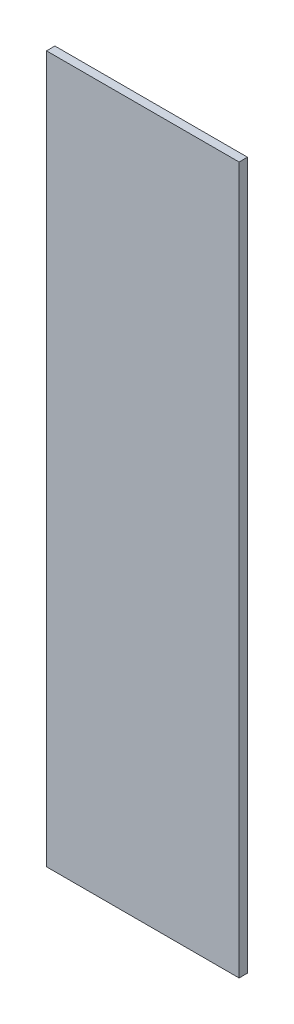
from build123d import *

# Parameters (mm, degrees)
SKETCH3_W           = 73
SKETCH3_H           = 267.9
BOSS_EXTRUDE1_DEPTH = 3.175


with BuildPart() as part:
    # Sketch3 → Boss-Extrude1 (new body)
    with BuildSketch(Plane.XY):
        with Locations((-36.5, 133.95)):
            Rectangle(SKETCH3_W, SKETCH3_H)
    extrude(amount=BOSS_EXTRUDE1_DEPTH)


solid = part.part
